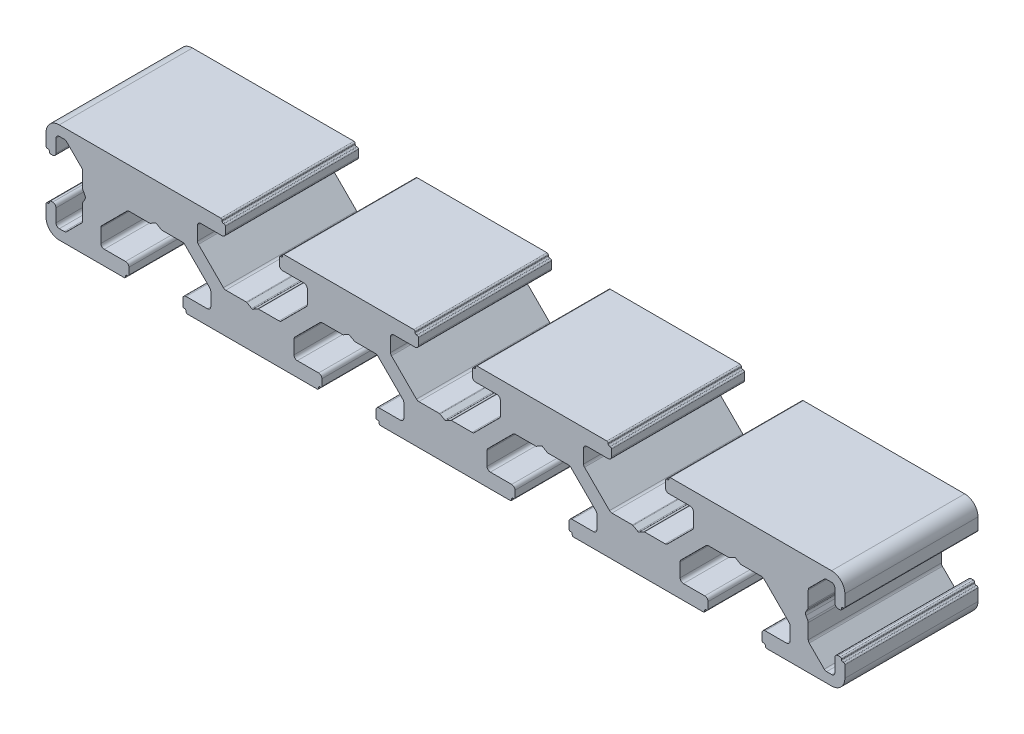
from build123d import *

# Parameters (mm, degrees)
EXTRUDE_1_DEPTH      = 10
EXTRUDE_1_DEPTH_BACK = 10


with BuildPart() as part:
    # Model → Extrude 1 (new body, two sides)
    with BuildSketch(Plane.XY) as extrude_1_sk:
        with BuildLine():
            Line((80.378942305, 100.304201932), (79.659327978, 99.888731481))
            ThreePointArc((79.659327978, 99.888731481), (79.611091046, 99.868750612), (79.559326285, 99.861935468))
            Line((79.559326285, 99.861935468), (76.482102388, 99.861935468))
            ThreePointArc((76.482102388, 99.861935468), (76.290761403, 99.823875841), (76.128549987, 99.715490581))
            Line((76.128549987, 99.715490581), (72.375387066, 95.962331386))
            ThreePointArc((72.375387066, 95.962331386), (72.267003811, 95.800119541), (72.228945905, 95.608778985))
            Line((72.228945905, 95.608778985), (72.228945905, 93.561936857))
            ThreePointArc((72.228945905, 93.561936857), (72.37538988, 93.208385087), (72.728939467, 93.061935843))
            Line((72.728939467, 93.061935843), (75.928941482, 93.061935843))
            ThreePointArc((75.928941482, 93.061935843), (76.282494569, 92.915490551), (76.428942495, 92.561938555))
            Line((76.428942495, 92.561938555), (76.428942495, 91.561936529))
            ThreePointArc((76.428942495, 91.561936529), (76.370361217, 91.420516604), (76.22893911, 91.361940594))
            Line((76.22893911, 91.361940594), (76.128944868, 91.361940594))
            ThreePointArc((76.128944868, 91.361940594), (75.987520126, 91.30336195), (75.928941482, 91.161937208))
            Line((75.928941482, 91.161937208), (75.928941482, 91.061935516))
            ThreePointArc((75.928941482, 91.061935516), (75.870362838, 90.920518224), (75.728945547, 90.861939581))
            Line((75.728945547, 90.861939581), (65.978944415, 90.861939581))
            ThreePointArc((65.978944415, 90.861939581), (64.564729433, 91.447723384), (63.978940361, 92.861936183))
            Line((63.978940361, 92.861936183), (63.978940361, 94.611936004))
            ThreePointArc((63.978940361, 94.611936004), (64.037520322, 94.753358338), (64.178943747, 94.811935665))
            Line((64.178943747, 94.811935665), (64.27894544, 94.811935665))
            ThreePointArc((64.27894544, 94.811935665), (64.420364048, 94.870515625), (64.478941375, 95.011935325))
            Line((64.478941375, 95.011935325), (64.478941375, 95.111937018))
            ThreePointArc((64.478941375, 95.111937018), (64.537521336, 95.253359351), (64.67894476, 95.311936678))
            Line((64.67894476, 95.311936678), (64.978942388, 95.311936678))
            ThreePointArc((64.978942388, 95.311936678), (65.332496792, 95.165490068), (65.478943401, 94.811935665))
            Line((65.478943401, 94.811935665), (65.478943401, 92.861936183))
            ThreePointArc((65.478943401, 92.861936183), (65.625391754, 92.508385705), (65.978944415, 92.36193517))
            Line((65.978944415, 92.36193517), (66.721834355, 92.36193517))
            ThreePointArc((66.721834355, 92.36193517), (66.91317577, 92.399996518), (67.075386756, 92.508383782))
            Line((67.075386756, 92.508383782), (69.332495445, 94.765488745))
            ThreePointArc((69.332495445, 94.765488745), (69.440883421, 94.927701453), (69.478944057, 95.119044872))
            Line((69.478944057, 95.119044872), (69.478944057, 97.361937852))
            ThreePointArc((69.478944057, 97.361937852), (69.495981499, 97.491347698), (69.545932227, 97.611938359))
            Line((69.545932227, 97.611938359), (69.834604972, 98.111935647))
            ThreePointArc((69.834604972, 98.111935647), (69.901592563, 98.361936153), (69.834604972, 98.61193666))
            Line((69.834604972, 98.61193666), (69.545932227, 99.111937673))
            ThreePointArc((69.545932227, 99.111937673), (69.495981499, 99.232528334), (69.478944057, 99.36193818))
            Line((69.478944057, 99.36193818), (69.478944057, 101.604831161))
            ThreePointArc((69.478944057, 101.604831161), (69.440882709, 101.796172575), (69.332495445, 101.958383562))
            Line((69.332495445, 101.958383562), (67.075386756, 104.21549225))
            ThreePointArc((67.075386756, 104.21549225), (66.913175341, 104.323877509), (66.721834355, 104.361937137))
            Line((66.721834355, 104.361937137), (65.978944415, 104.361937137))
            ThreePointArc((65.978944415, 104.361937137), (65.625390011, 104.215490527), (65.478943401, 103.861936124))
            Line((65.478943401, 103.861936124), (65.478943401, 101.911936642))
            ThreePointArc((65.478943401, 101.911936642), (65.332496792, 101.558382238), (64.978942388, 101.411935629))
            Line((64.978942388, 101.411935629), (64.67894476, 101.411935629))
            ThreePointArc((64.67894476, 101.411935629), (64.537521336, 101.470512956), (64.478941375, 101.611935289))
            Line((64.478941375, 101.611935289), (64.478941375, 101.711936982))
            ThreePointArc((64.478941375, 101.711936982), (64.420364048, 101.853356681), (64.27894544, 101.911936642))
            Line((64.27894544, 101.911936642), (64.178943747, 101.911936642))
            ThreePointArc((64.178943747, 101.911936642), (64.037520322, 101.970513969), (63.978940361, 102.111936302))
            Line((63.978940361, 102.111936302), (63.978940361, 103.861936124))
            ThreePointArc((63.978940361, 103.861936124), (64.564730324, 105.276150215), (65.978944415, 105.861936451))
            Line((65.978944415, 105.861936451), (90.228941404, 105.861936451))
            ThreePointArc((90.228941404, 105.861936451), (90.370362421, 105.803357808), (90.428941065, 105.661936791))
            Line((90.428941065, 105.661936791), (90.428941065, 105.561938824))
            ThreePointArc((90.428941065, 105.561938824), (90.487519708, 105.420514082), (90.62894445, 105.361935438))
            Line((90.62894445, 105.361935438), (90.728942418, 105.361935438))
            ThreePointArc((90.728942418, 105.361935438), (90.870363434, 105.303356794), (90.928942078, 105.161935778))
            Line((90.928942078, 105.161935778), (90.928942078, 104.161937477))
            ThreePointArc((90.928942078, 104.161937477), (90.782495469, 103.808383073), (90.428941065, 103.661936463))
            Line((90.428941065, 103.661936463), (87.228946501, 103.661936463))
            ThreePointArc((87.228946501, 103.661936463), (86.875392097, 103.515489854), (86.728945487, 103.16193545))
            Line((86.728945487, 103.16193545), (86.728945487, 101.115093322))
            ThreePointArc((86.728945487, 101.115093322), (86.767003394, 100.923752766), (86.875386649, 100.761540921))
            Line((86.875386649, 100.761540921), (90.628545844, 97.008385451))
            ThreePointArc((90.628545844, 97.008385451), (90.790758552, 96.899997474), (90.982101971, 96.861936839))
            Line((90.982101971, 96.861936839), (94.059325868, 96.861936839))
            ThreePointArc((94.059325868, 96.861936839), (94.111090629, 96.855121695), (94.15932756, 96.835140826))
            Line((94.15932756, 96.835140826), (94.878941887, 96.419670375))
            ThreePointArc((94.878941887, 96.419670375), (94.978941717, 96.392875553), (95.078941548, 96.419670375))
            Line((95.078941548, 96.419670375), (95.7985596, 96.835140826))
            ThreePointArc((95.7985596, 96.835140826), (95.846794732, 96.855121213), (95.898557567, 96.861936839))
            Line((95.898557567, 96.861936839), (98.97578519, 96.861936839))
            ThreePointArc((98.97578519, 96.861936839), (99.167126604, 96.899998187), (99.329337591, 97.008385451))
            Line((99.329337591, 97.008385451), (103.082496786, 100.761540921))
            ThreePointArc((103.082496786, 100.761540921), (103.190882045, 100.923752337), (103.228941673, 101.115093322))
            Line((103.228941673, 101.115093322), (103.228941673, 103.16193545))
            ThreePointArc((103.228941673, 103.16193545), (103.08249638, 103.515488537), (102.728944385, 103.661936463))
            Line((102.728944385, 103.661936463), (99.52894237, 103.661936463))
            ThreePointArc((99.52894237, 103.661936463), (99.175387966, 103.808383073), (99.028941357, 104.161937477))
            Line((99.028941357, 104.161937477), (99.028941357, 105.161935778))
            ThreePointArc((99.028941357, 105.161935778), (99.087520001, 105.303356794), (99.228941017, 105.361935438))
            Line((99.228941017, 105.361935438), (99.32894271, 105.361935438))
            ThreePointArc((99.32894271, 105.361935438), (99.470365043, 105.420515399), (99.52894237, 105.561938824))
            Line((99.52894237, 105.561938824), (99.52894237, 105.661936791))
            ThreePointArc((99.52894237, 105.661936791), (99.587521014, 105.803357808), (99.72894203, 105.861936451))
            Line((99.72894203, 105.861936451), (119.228944295, 105.861936451))
            ThreePointArc((119.228944295, 105.861936451), (119.370365312, 105.803357808), (119.428943956, 105.661936791))
            Line((119.428943956, 105.661936791), (119.428943956, 105.561938824))
            ThreePointArc((119.428943956, 105.561938824), (119.487521282, 105.420515399), (119.628943616, 105.361935438))
            Line((119.628943616, 105.361935438), (119.728943446, 105.361935438))
            ThreePointArc((119.728943446, 105.361935438), (119.870364462, 105.303356794), (119.928943106, 105.161935778))
            Line((119.928943106, 105.161935778), (119.928943106, 104.161937477))
            ThreePointArc((119.928943106, 104.161937477), (119.782497155, 103.808383731), (119.428943956, 103.661936463))
            Line((119.428943956, 103.661936463), (116.228941941, 103.661936463))
            ThreePointArc((116.228941941, 103.661936463), (115.875387537, 103.515489854), (115.728940928, 103.16193545))
            Line((115.728940928, 103.16193545), (115.728940928, 101.115093322))
            ThreePointArc((115.728940928, 101.115093322), (115.767002276, 100.923751907), (115.87538954, 100.761540921))
            Line((115.87538954, 100.761540921), (119.628546872, 97.008385451))
            ThreePointArc((119.628546872, 97.008385451), (119.790758719, 96.899997831), (119.982101136, 96.861936839))
            Line((119.982101136, 96.861936839), (123.059326896, 96.861936839))
            ThreePointArc((123.059326896, 96.861936839), (123.111090694, 96.855121454), (123.159326726, 96.835140826))
            Line((123.159326726, 96.835140826), (123.878942915, 96.419670375))
            ThreePointArc((123.878942915, 96.419670375), (123.978942746, 96.392875553), (124.078942576, 96.419670375))
            Line((124.078942576, 96.419670375), (124.798558765, 96.835140826))
            ThreePointArc((124.798558765, 96.835140826), (124.846794797, 96.855121454), (124.898558595, 96.861936839))
            Line((124.898558595, 96.861936839), (127.975784355, 96.861936839))
            ThreePointArc((127.975784355, 96.861936839), (128.167126772, 96.899997831), (128.329338619, 97.008385451))
            Line((128.329338619, 97.008385451), (132.082495951, 100.761540921))
            ThreePointArc((132.082495951, 100.761540921), (132.190882213, 100.923752122), (132.228942701, 101.115093322))
            Line((132.228942701, 101.115093322), (132.228942701, 103.16193545))
            ThreePointArc((132.228942701, 103.16193545), (132.08249675, 103.515489195), (131.72894355, 103.661936463))
            Line((131.72894355, 103.661936463), (128.528943398, 103.661936463))
            ThreePointArc((128.528943398, 103.661936463), (128.175388994, 103.808383073), (128.028942385, 104.161937477))
            Line((128.028942385, 104.161937477), (128.028942385, 105.161935778))
            ThreePointArc((128.028942385, 105.161935778), (128.087521029, 105.303356794), (128.228942045, 105.361935438))
            Line((128.228942045, 105.361935438), (128.328941875, 105.361935438))
            ThreePointArc((128.328941875, 105.361935438), (128.470365413, 105.42051474), (128.528943398, 105.561938824))
            Line((128.528943398, 105.561938824), (128.528943398, 105.661936791))
            ThreePointArc((128.528943398, 105.661936791), (128.587522042, 105.803357808), (128.728943059, 105.861936451))
            Line((128.728943059, 105.861936451), (148.228942762, 105.861936451))
            ThreePointArc((148.228942762, 105.861936451), (148.37036408, 105.803357972), (148.428942888, 105.661936791))
            Line((148.428942888, 105.661936791), (148.428942888, 105.561938824))
            ThreePointArc((148.428942888, 105.561938824), (148.487520297, 105.420515317), (148.628942781, 105.361935438))
            Line((148.628942781, 105.361935438), (148.728942844, 105.361935438))
            ThreePointArc((148.728942844, 105.361935438), (148.870364011, 105.303356877), (148.928942737, 105.161935778))
            Line((148.928942737, 105.161935778), (148.928942737, 104.161937477))
            ThreePointArc((148.928942737, 104.161937477), (148.78249654, 103.808383484), (148.428942888, 103.661936463))
            Line((148.428942888, 103.661936463), (145.228942969, 103.661936463))
            ThreePointArc((145.228942969, 103.661936463), (144.875389167, 103.515489525), (144.728942887, 103.16193545))
            Line((144.728942887, 103.16193545), (144.728942887, 101.115093322))
            ThreePointArc((144.728942887, 101.115093322), (144.76700316, 100.923752176), (144.875389171, 100.761540921))
            Line((144.875389171, 100.761540921), (148.628547435, 97.008385451))
            ThreePointArc((148.628547435, 97.008385451), (148.790758852, 96.899998009), (148.982100767, 96.861936839))
            Line((148.982100767, 96.861936839), (152.059327575, 96.861936839))
            ThreePointArc((152.059327575, 96.861936839), (152.111091433, 96.855121469), (152.159327521, 96.835140826))
            Line((152.159327521, 96.835140826), (152.878942779, 96.419670375))
            ThreePointArc((152.878942779, 96.419670375), (152.978942726, 96.392875486), (153.078942673, 96.419670375))
            Line((153.078942673, 96.419670375), (153.798557931, 96.835140826))
            ThreePointArc((153.798557931, 96.835140826), (153.846794075, 96.855121484), (153.898557994, 96.861936839))
            Line((153.898557994, 96.861936839), (156.975784918, 96.861936839))
            ThreePointArc((156.975784918, 96.861936839), (157.167126833, 96.899998009), (157.32933825, 97.008385451))
            Line((157.32933825, 97.008385451), (161.082496048, 100.761540921))
            ThreePointArc((161.082496048, 100.761540921), (161.19088231, 100.923752122), (161.228942798, 101.115093322))
            Line((161.228942798, 101.115093322), (161.228942798, 103.16193545))
            ThreePointArc((161.228942798, 103.16193545), (161.082496518, 103.515489525), (160.728942716, 103.661936463))
            Line((160.728942716, 103.661936463), (157.528942564, 103.661936463))
            ThreePointArc((157.528942564, 103.661936463), (157.175389063, 103.808383567), (157.028942947, 104.161937477))
            Line((157.028942947, 104.161937477), (157.028942947, 105.161935778))
            ThreePointArc((157.028942947, 105.161935778), (157.087521591, 105.303356794), (157.228942608, 105.361935438))
            Line((157.228942608, 105.361935438), (157.328942904, 105.361935438))
            ThreePointArc((157.328942904, 105.361935438), (157.470365237, 105.420515399), (157.528942564, 105.561938824))
            Line((157.528942564, 105.561938824), (157.528942564, 105.661936791))
            ThreePointArc((157.528942564, 105.661936791), (157.587521372, 105.803357972), (157.72894269, 105.861936451))
            Line((157.72894269, 105.861936451), (181.978942939, 105.861936451))
            ThreePointArc((181.978942939, 105.861936451), (183.393155625, 105.276149355), (183.978941404, 103.861936124))
            Line((183.978941404, 103.861936124), (183.978941404, 102.111936302))
            ThreePointArc((183.978941404, 102.111936302), (183.920362761, 101.970515286), (183.778941744, 101.911936642))
            Line((183.778941744, 101.911936642), (183.678943777, 101.911936642))
            ThreePointArc((183.678943777, 101.911936642), (183.53752276, 101.853357998), (183.478944116, 101.711936982))
            Line((183.478944116, 101.711936982), (183.478944116, 101.611935289))
            ThreePointArc((183.478944116, 101.611935289), (183.420365473, 101.470514273), (183.278944456, 101.411935629))
            Line((183.278944456, 101.411935629), (182.978943103, 101.411935629))
            ThreePointArc((182.978943103, 101.411935629), (182.625388699, 101.558382238), (182.47894209, 101.911936642))
            Line((182.47894209, 101.911936642), (182.47894209, 103.861936124))
            ThreePointArc((182.47894209, 103.861936124), (182.332495938, 104.215489668), (181.978942939, 104.361937137))
            Line((181.978942939, 104.361937137), (181.236049273, 104.361937137))
            ThreePointArc((181.236049273, 104.361937137), (181.044708288, 104.323877509), (180.882496872, 104.21549225))
            Line((180.882496872, 104.21549225), (178.625390046, 101.958383562))
            ThreePointArc((178.625390046, 101.958383562), (178.517003785, 101.79617236), (178.478943297, 101.604831161))
            Line((178.478943297, 101.604831161), (178.478943297, 99.36193818))
            ThreePointArc((178.478943297, 99.36193818), (178.461905854, 99.232528334), (178.411955127, 99.111937673))
            Line((178.411955127, 99.111937673), (178.123280519, 98.61193666))
            ThreePointArc((178.123280519, 98.61193666), (178.056292928, 98.361936153), (178.123280519, 98.111935647))
            Line((178.123280519, 98.111935647), (178.411955127, 97.611938359))
            ThreePointArc((178.411955127, 97.611938359), (178.461905854, 97.491347698), (178.478943297, 97.361937852))
            Line((178.478943297, 97.361937852), (178.478943297, 95.119044872))
            ThreePointArc((178.478943297, 95.119044872), (178.517003072, 94.927701667), (178.625390046, 94.765488745))
            Line((178.625390046, 94.765488745), (180.882496872, 92.508383782))
            ThreePointArc((180.882496872, 92.508383782), (181.044707859, 92.399996518), (181.236049273, 92.36193517))
            Line((181.236049273, 92.36193517), (181.978942939, 92.36193517))
            ThreePointArc((181.978942939, 92.36193517), (182.332496139, 92.508382438), (182.47894209, 92.861936183))
            Line((182.47894209, 92.861936183), (182.47894209, 94.811935665))
            ThreePointArc((182.47894209, 94.811935665), (182.625388699, 95.165490068), (182.978943103, 95.311936678))
            Line((182.978943103, 95.311936678), (183.278944456, 95.311936678))
            ThreePointArc((183.278944456, 95.311936678), (183.420365473, 95.253358034), (183.478944116, 95.111937018))
            Line((183.478944116, 95.111937018), (183.478944116, 95.011935325))
            ThreePointArc((183.478944116, 95.011935325), (183.53752276, 94.870514308), (183.678943777, 94.811935665))
            Line((183.678943777, 94.811935665), (183.778941744, 94.811935665))
            ThreePointArc((183.778941744, 94.811935665), (183.920362761, 94.753357021), (183.978941404, 94.611936004))
            Line((183.978941404, 94.611936004), (183.978941404, 92.861936183))
            ThreePointArc((183.978941404, 92.861936183), (183.393153192, 91.447725385), (181.978942939, 90.861939581))
            Line((181.978942939, 90.861939581), (172.228943669, 90.861939581))
            ThreePointArc((172.228943669, 90.861939581), (172.087522766, 90.920516249), (172.028942147, 91.061935516))
            Line((172.028942147, 91.061935516), (172.028942147, 91.161937208))
            ThreePointArc((172.028942147, 91.161937208), (171.97036482, 91.303360633), (171.828942486, 91.361940594))
            Line((171.828942486, 91.361940594), (171.728942656, 91.361940594))
            ThreePointArc((171.728942656, 91.361940594), (171.587522957, 91.420517921), (171.528942996, 91.561936529))
            Line((171.528942996, 91.561936529), (171.528942996, 92.561938555))
            ThreePointArc((171.528942996, 92.561938555), (171.675390264, 92.915489893), (172.028942147, 93.061935843))
            Line((172.028942147, 93.061935843), (175.228942299, 93.061935843))
            ThreePointArc((175.228942299, 93.061935843), (175.582496702, 93.208382453), (175.728943312, 93.561936857))
            Line((175.728943312, 93.561936857), (175.728943312, 95.608778985))
            ThreePointArc((175.728943312, 95.608778985), (175.690882824, 95.800120185), (175.582496562, 95.962331386))
            Line((175.582496562, 95.962331386), (171.829337367, 99.715490581))
            ThreePointArc((171.829337367, 99.715490581), (171.667125951, 99.823875841), (171.475784966, 99.861935468))
            Line((171.475784966, 99.861935468), (168.398557344, 99.861935468))
            ThreePointArc((168.398557344, 99.861935468), (168.346793546, 99.868750853), (168.298557514, 99.888731481))
            Line((168.298557514, 99.888731481), (167.578943187, 100.304201932))
            ThreePointArc((167.578943187, 100.304201932), (167.478943357, 100.330996753), (167.378943526, 100.304201932))
            Line((167.378943526, 100.304201932), (166.659327337, 99.888731481))
            ThreePointArc((166.659327337, 99.888731481), (166.611091305, 99.868750853), (166.559327507, 99.861935468))
            Line((166.559327507, 99.861935468), (163.482100816, 99.861935468))
            ThreePointArc((163.482100816, 99.861935468), (163.290759329, 99.823876019), (163.128547483, 99.715490581))
            Line((163.128547483, 99.715490581), (159.375389219, 95.962331386))
            ThreePointArc((159.375389219, 95.962331386), (159.267002958, 95.800120185), (159.22894247, 95.608778985))
            Line((159.22894247, 95.608778985), (159.22894247, 93.561936857))
            ThreePointArc((159.22894247, 93.561936857), (159.37538875, 93.208382782), (159.728942552, 93.061935843))
            Line((159.728942552, 93.061935843), (162.928942704, 93.061935843))
            ThreePointArc((162.928942704, 93.061935843), (163.282495189, 92.915490222), (163.428942786, 92.561938555))
            Line((163.428942786, 92.561938555), (163.428942786, 91.561936529))
            ThreePointArc((163.428942786, 91.561936529), (163.370362825, 91.420517921), (163.228943126, 91.361940594))
            Line((163.228943126, 91.361940594), (163.128942364, 91.361940594))
            ThreePointArc((163.128942364, 91.361940594), (162.987520031, 91.303360633), (162.928942704, 91.161937208))
            Line((162.928942704, 91.161937208), (162.928942704, 91.061935516))
            ThreePointArc((162.928942704, 91.061935516), (162.870362743, 90.920516907), (162.728943044, 90.861939581))
            Line((162.728943044, 90.861939581), (143.228942641, 90.861939581))
            ThreePointArc((143.228942641, 90.861939581), (143.087522942, 90.920516907), (143.028942981, 91.061935516))
            Line((143.028942981, 91.061935516), (143.028942981, 91.161937208))
            ThreePointArc((143.028942981, 91.161937208), (142.970365325, 91.303360962), (142.828942389, 91.361940594))
            Line((142.828942389, 91.361940594), (142.728942559, 91.361940594))
            ThreePointArc((142.728942559, 91.361940594), (142.58752286, 91.420517921), (142.528942899, 91.561936529))
            Line((142.528942899, 91.561936529), (142.528942899, 92.561938555))
            ThreePointArc((142.528942899, 92.561938555), (142.675390496, 92.915490222), (143.028942981, 93.061935843))
            Line((143.028942981, 93.061935843), (146.228942667, 93.061935843))
            ThreePointArc((146.228942667, 93.061935843), (146.582496469, 93.208382782), (146.728942749, 93.561936857))
            Line((146.728942749, 93.561936857), (146.728942749, 95.608778985))
            ThreePointArc((146.728942749, 95.608778985), (146.690882261, 95.800120185), (146.582496, 95.962331386))
            Line((146.582496, 95.962331386), (142.829338202, 99.715490581))
            ThreePointArc((142.829338202, 99.715490581), (142.667126356, 99.823876019), (142.475784869, 99.861935468))
            Line((142.475784869, 99.861935468), (139.398558178, 99.861935468))
            ThreePointArc((139.398558178, 99.861935468), (139.34679438, 99.868750853), (139.298558348, 99.888731481))
            Line((139.298558348, 99.888731481), (138.57894309, 100.304201932))
            ThreePointArc((138.57894309, 100.304201932), (138.478942794, 100.330997022), (138.378942498, 100.304201932))
            Line((138.378942498, 100.304201932), (137.65932724, 99.888731481))
            ThreePointArc((137.65932724, 99.888731481), (137.611091208, 99.868750853), (137.55932741, 99.861935468))
            Line((137.55932741, 99.861935468), (134.482100719, 99.861935468))
            ThreePointArc((134.482100719, 99.861935468), (134.290759734, 99.823875841), (134.128548318, 99.715490581))
            Line((134.128548318, 99.715490581), (130.375389123, 95.962331386))
            ThreePointArc((130.375389123, 95.962331386), (130.267002861, 95.800120185), (130.228942373, 95.608778985))
            Line((130.228942373, 95.608778985), (130.228942373, 93.561936857))
            ThreePointArc((130.228942373, 93.561936857), (130.375388982, 93.208382453), (130.728943386, 93.061935843))
            Line((130.728943386, 93.061935843), (133.928943538, 93.061935843))
            ThreePointArc((133.928943538, 93.061935843), (134.282495421, 92.915489893), (134.428942689, 92.561938555))
            Line((134.428942689, 92.561938555), (134.428942689, 91.561936529))
            ThreePointArc((134.428942689, 91.561936529), (134.370362728, 91.420517921), (134.228943029, 91.361940594))
            Line((134.228943029, 91.361940594), (134.128943199, 91.361940594))
            ThreePointArc((134.128943199, 91.361940594), (133.987520865, 91.303360633), (133.928943538, 91.161937208))
            Line((133.928943538, 91.161937208), (133.928943538, 91.061935516))
            ThreePointArc((133.928943538, 91.061935516), (133.870362919, 90.920516249), (133.728942015, 90.861939581))
            Line((133.728942015, 90.861939581), (114.228941613, 90.861939581))
            ThreePointArc((114.228941613, 90.861939581), (114.087521914, 90.920516907), (114.028941953, 91.061935516))
            Line((114.028941953, 91.061935516), (114.028941953, 91.161937208))
            ThreePointArc((114.028941953, 91.161937208), (113.970364626, 91.303360633), (113.828942293, 91.361940594))
            Line((113.828942293, 91.361940594), (113.728944325, 91.361940594))
            ThreePointArc((113.728944325, 91.361940594), (113.587522217, 91.420516604), (113.52894094, 91.561936529))
            Line((113.52894094, 91.561936529), (113.52894094, 92.561938555))
            ThreePointArc((113.52894094, 92.561938555), (113.675388866, 92.915490551), (114.028941953, 93.061935843))
            Line((114.028941953, 93.061935843), (117.228943967, 93.061935843))
            ThreePointArc((117.228943967, 93.061935843), (117.582495963, 93.20838377), (117.728941255, 93.561936857))
            Line((117.728941255, 93.561936857), (117.728941255, 95.608778985))
            ThreePointArc((117.728941255, 95.608778985), (117.690881628, 95.80011997), (117.582496369, 95.962331386))
            Line((117.582496369, 95.962331386), (113.829337173, 99.715490581))
            ThreePointArc((113.829337173, 99.715490581), (113.667125758, 99.823875841), (113.475784772, 99.861935468))
            Line((113.475784772, 99.861935468), (110.39855715, 99.861935468))
            ThreePointArc((110.39855715, 99.861935468), (110.346794315, 99.868751094), (110.298559183, 99.888731481))
            Line((110.298559183, 99.888731481), (109.57894113, 100.304201932))
            ThreePointArc((109.57894113, 100.304201932), (109.4789413, 100.330996753), (109.37894147, 100.304201932))
            Line((109.37894147, 100.304201932), (108.659327143, 99.888731481))
            ThreePointArc((108.659327143, 99.888731481), (108.611092011, 99.868751094), (108.559329176, 99.861935468))
            Line((108.559329176, 99.861935468), (105.482101553, 99.861935468))
            ThreePointArc((105.482101553, 99.861935468), (105.290760568, 99.823875841), (105.128549152, 99.715490581))
            Line((105.128549152, 99.715490581), (101.375389957, 95.962331386))
            ThreePointArc((101.375389957, 95.962331386), (101.267002693, 95.800120399), (101.228941345, 95.608778985))
            Line((101.228941345, 95.608778985), (101.228941345, 93.561936857))
            ThreePointArc((101.228941345, 93.561936857), (101.375387954, 93.208382453), (101.728942358, 93.061935843))
            Line((101.728942358, 93.061935843), (104.928944373, 93.061935843))
            ThreePointArc((104.928944373, 93.061935843), (105.282495051, 92.915489234), (105.428941661, 92.561938555))
            Line((105.428941661, 92.561938555), (105.428941661, 91.561936529))
            ThreePointArc((105.428941661, 91.561936529), (105.3703617, 91.420517921), (105.228942001, 91.361940594))
            Line((105.228942001, 91.361940594), (105.128944033, 91.361940594))
            ThreePointArc((105.128944033, 91.361940594), (104.987521699, 91.303360633), (104.928944373, 91.161937208))
            Line((104.928944373, 91.161937208), (104.928944373, 91.061935516))
            ThreePointArc((104.928944373, 91.061935516), (104.870363095, 90.92051559), (104.728940987, 90.861939581))
            Line((104.728940987, 90.861939581), (85.228942448, 90.861939581))
            ThreePointArc((85.228942448, 90.861939581), (85.08752034, 90.92051559), (85.028939062, 91.061935516))
            Line((85.028939062, 91.061935516), (85.028939062, 91.161937208))
            ThreePointArc((85.028939062, 91.161937208), (84.970363052, 91.303359316), (84.828943127, 91.361940594))
            Line((84.828943127, 91.361940594), (84.728941434, 91.361940594))
            ThreePointArc((84.728941434, 91.361940594), (84.587524143, 91.420519238), (84.528945499, 91.561936529))
            Line((84.528945499, 91.561936529), (84.528945499, 92.561938555))
            ThreePointArc((84.528945499, 92.561938555), (84.675390792, 92.915487917), (85.028939062, 93.061935843))
            Line((85.028939062, 93.061935843), (88.228941077, 93.061935843))
            ThreePointArc((88.228941077, 93.061935843), (88.582495481, 93.208382453), (88.72894209, 93.561936857))
            Line((88.72894209, 93.561936857), (88.72894209, 95.608778985))
            ThreePointArc((88.72894209, 95.608778985), (88.690882463, 95.80011997), (88.582497203, 95.962331386))
            Line((88.582497203, 95.962331386), (84.829338008, 99.715490581))
            ThreePointArc((84.829338008, 99.715490581), (84.667126592, 99.823875841), (84.475785607, 99.861935468))
            Line((84.475785607, 99.861935468), (81.39856171, 99.861935468))
            ThreePointArc((81.39856171, 99.861935468), (81.346796949, 99.868750612), (81.298560017, 99.888731481))
            Line((81.298560017, 99.888731481), (80.57894569, 100.304201932))
            ThreePointArc((80.57894569, 100.304201932), (80.478943997, 100.330997829), (80.378942305, 100.304201932))
        make_face()
    extrude(amount=EXTRUDE_1_DEPTH)
    extrude(extrude_1_sk.sketch, amount=-EXTRUDE_1_DEPTH_BACK)


solid = part.part
